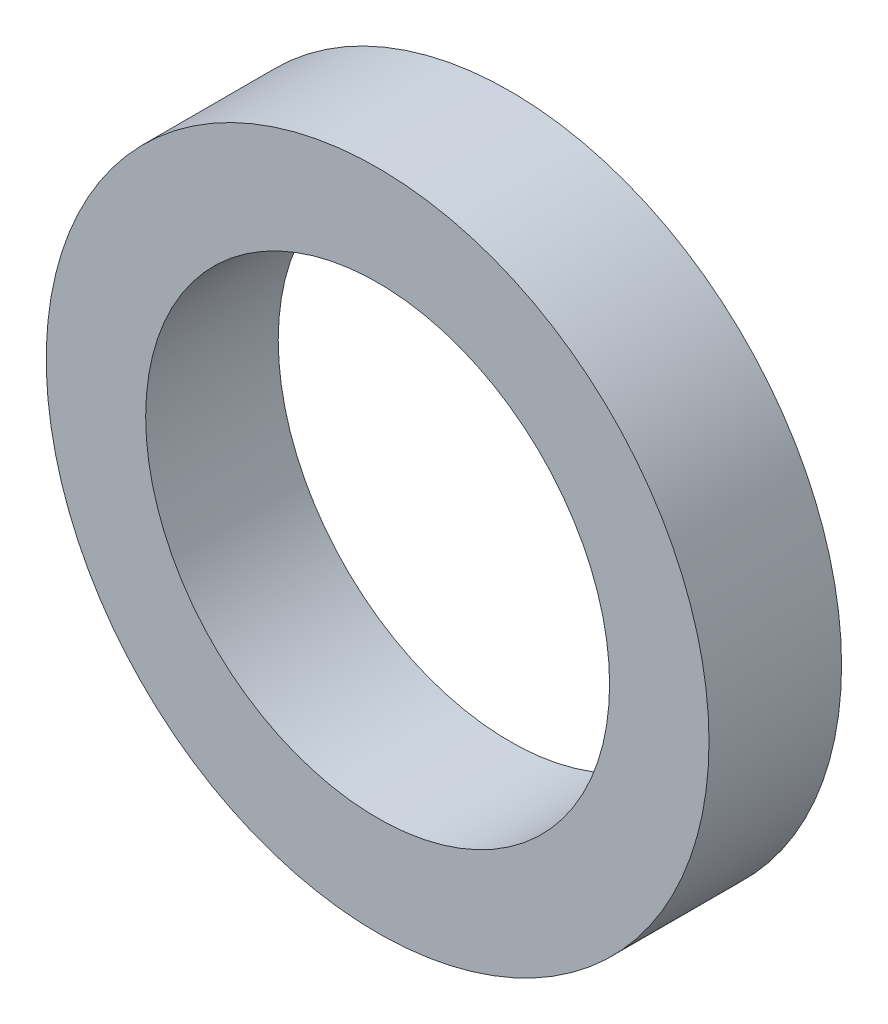
from build123d import *

# Parameters (mm, degrees)
SKETCH1_R           = 10
SKETCH1_R_2         = 7
BOSS_EXTRUDE1_DEPTH = 4


with BuildPart() as part:
    # Sketch1 → Boss-Extrude1 (new body)
    with BuildSketch(Plane.XY):
        Circle(SKETCH1_R)
        Circle(SKETCH1_R_2, mode=Mode.SUBTRACT)
    extrude(amount=BOSS_EXTRUDE1_DEPTH)


solid = part.part
